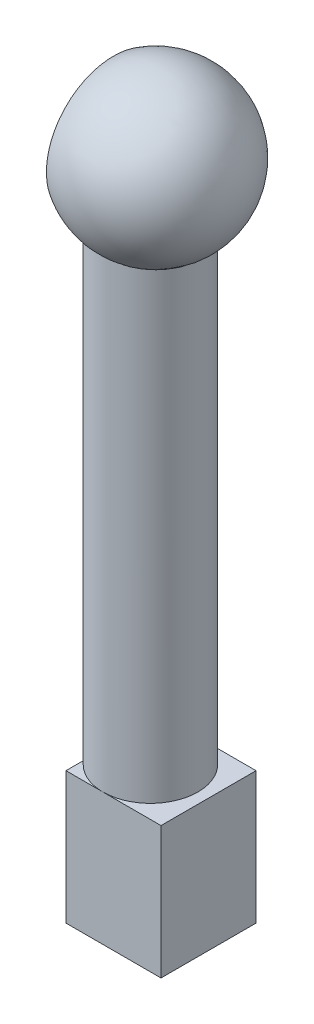
from build123d import *

# Parameters (mm, degrees)
SKETCH1_W           = 18
SKETCH1_H           = 25
BOSS_EXTRUDE1_DEPTH = 18
SKETCH2_W           = 7
SKETCH2_H           = 12.4
CUT_EXTRUDE1_DEPTH  = 20
BOSS_EXTRUDE2_DEPTH = 100
CUT_EXTRUDE2_DEPTH  = 100


with BuildPart() as part:
    # Sketch1 → Boss-Extrude1 (new body)
    with BuildSketch(Plane(origin=(0, 0, 0), x_dir=(0, 0, -1), z_dir=(1, 0, 0))):
        Rectangle(SKETCH1_W, SKETCH1_H)
    extrude(amount=BOSS_EXTRUDE1_DEPTH)

    # Sketch2 → Cut-Extrude1 (cut)
    with BuildSketch(Plane.XZ.offset(12.5)):
        with Locations((12, 0)):
            Rectangle(SKETCH2_W, SKETCH2_H)
    extrude(amount=-CUT_EXTRUDE1_DEPTH, mode=Mode.SUBTRACT)

    # Sketch3 → Boss-Extrude2 (add)
    with BuildSketch(Plane(origin=(0, 12.5, 0), x_dir=(1, 0, 0), z_dir=(0, 1, 0))):
        with BuildLine():
            Line((0, 5.656854249), (0, -5.656854249))
            ThreePointArc((0, -5.656854249), (16, 0), (0, 5.656854249))
        make_face()
    extrude(amount=BOSS_EXTRUDE2_DEPTH)

    # Sketch6 → Revolve2 (revolve)
    with BuildSketch(Plane(origin=(0, 112.5, 0), x_dir=(1, 0, 0), z_dir=(0, 1, 0))):
        with BuildLine():
            Line((8, 15), (8, -15))
            ThreePointArc((8, -15), (-7, 0), (8, 15))
        make_face()
    revolve(axis=Axis((8, 112.5, -15), (0, 0, 1)))

    # Sketch7 → Cut-Extrude2 (cut)
    with BuildSketch(Plane.ZY):
        with BuildLine():
            ThreePointArc((-5.656854249, 101.142183308), (0, 203.728611238), (5.656854249, 101.142183308))
            ThreePointArc((5.656854249, 101.142183308), (0, 99.81142246), (-5.656854249, 101.142183308))
        make_face()
    extrude(amount=CUT_EXTRUDE2_DEPTH, mode=Mode.SUBTRACT)


solid = part.part
